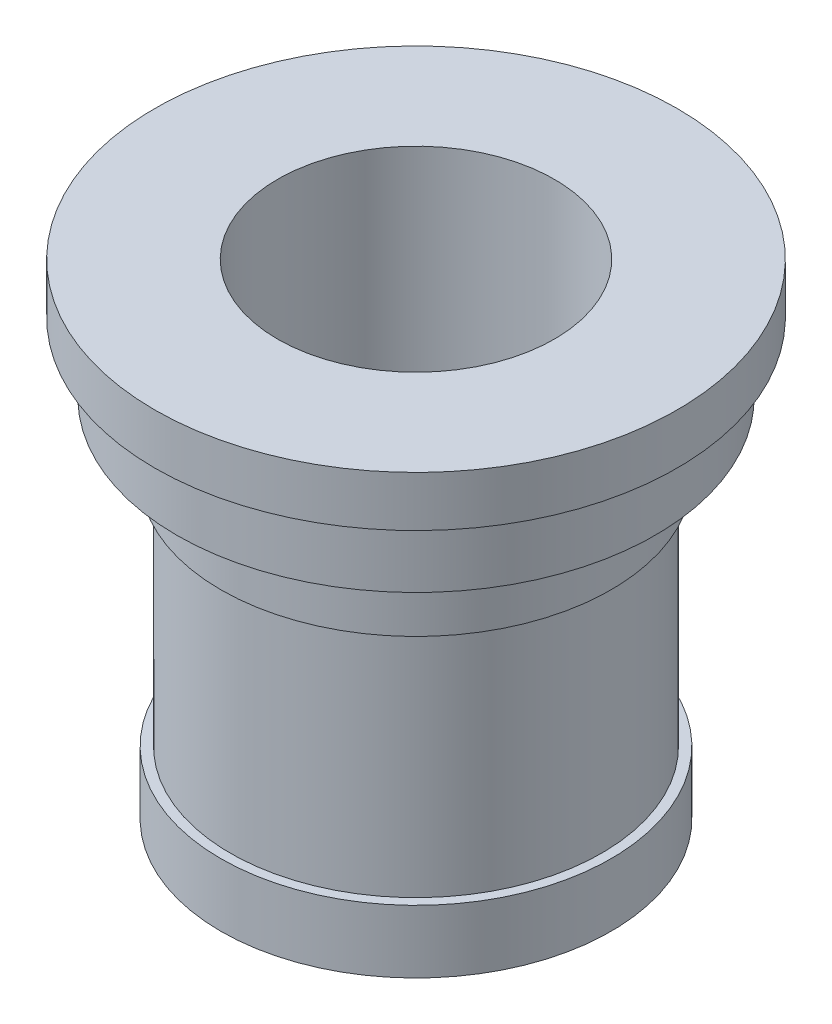
from build123d import *

# Parameters (mm, degrees)
SKETCH2_R          = 22
CUT_EXTRUDE1_DEPTH = 77


with BuildPart() as part:
    # Sketch1 → Revolve1 (revolve)
    with BuildSketch(Plane.XY, mode=Mode.PRIVATE) as revolve1_sk:
        Polygon((0, 0), (31, 0), (31, 10), (29.5, 10), (29.5, 47), (31, 47), (31, 58), (38, 58), (38, 69), (41.5, 69), (41.5, 77), (0, 77), align=None)
    revolve(revolve1_sk.sketch.rotate(Axis((0, 0, 0), (0, 1, 0)), 90), axis=Axis((0, 0, 0), (0, 1, 0)))  # turned: the seam where the file's is

    # Sketch2 → Cut-Extrude1 (cut)
    with BuildSketch(Plane(origin=(0, 77, 0), x_dir=(1, 0, 0), z_dir=(0, 1, 0))):
        with Locations(Location((0, 0, 0), (0, 0, 270))):  # turned: the seam where the file's is
            Circle(SKETCH2_R)
    extrude(amount=-CUT_EXTRUDE1_DEPTH, mode=Mode.SUBTRACT)


solid = part.part
